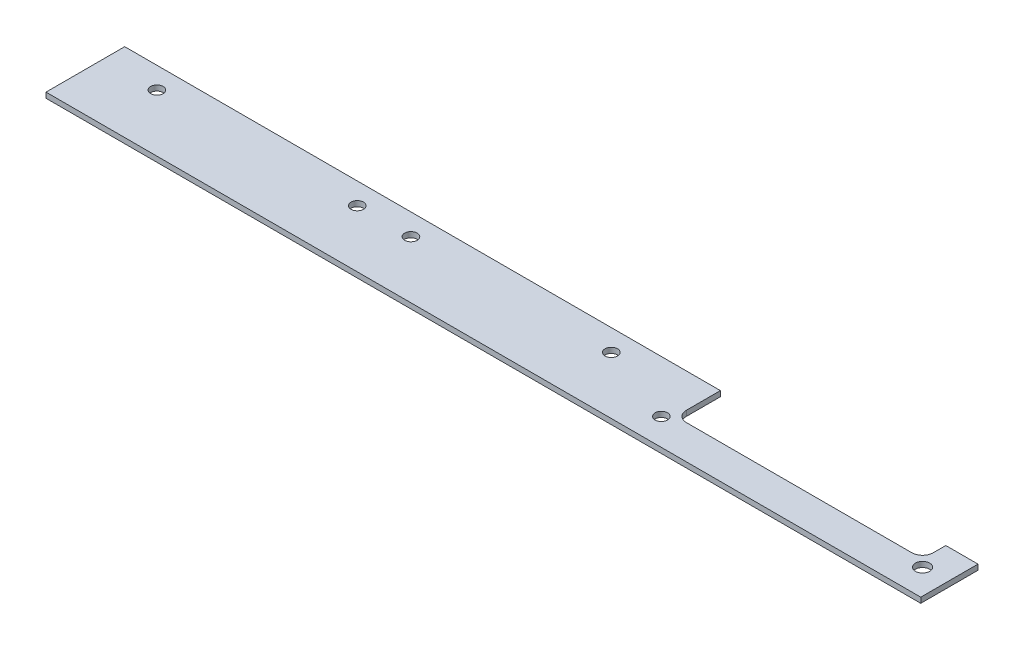
from build123d import *

# Parameters (mm, degrees)
SKETCH_1_R      = 1.75
SKETCH_1_R_2    = 2
EXTRUDE_1_DEPTH = 1.5


with BuildPart() as part:
    # Эскиз1 → Бобышка-Вытянуть1 (new body)
    with BuildSketch(Plane(origin=(0, 0, 0), x_dir=(1, 0, 0), z_dir=(0, 1, 0))):
        with BuildLine():
            Line((166.5, 12.5), (166.5, 22))
            Line((166.5, 22), (0, 22))
            Line((0, 22), (0, 0))
            Line((0, 0), (244.5, 0))
            Line((244.5, 0), (244.5, 16))
            Line((244.5, 16), (235.5, 16))
            Line((235.5, 16), (235.5, 12.5))
            ThreePointArc((235.5, 12.5), (234.621320344, 10.378679656), (232.5, 9.5))
            Line((232.5, 9.5), (169.5, 9.5))
            ThreePointArc((169.5, 9.5), (167.378679656, 10.378679656), (166.5, 12.5))
        make_face()
        with Locations((164.5, 7.5)):
            Circle(SKETCH_1_R, mode=Mode.SUBTRACT)
        with Locations((237.5, 7.5)):
            Circle(SKETCH_1_R_2, mode=Mode.SUBTRACT)
        with Locations((15, 16)):
            Circle(SKETCH_1_R, mode=Mode.SUBTRACT)
        with Locations((71, 16)):
            Circle(SKETCH_1_R, mode=Mode.SUBTRACT)
        with Locations((86, 16)):
            Circle(SKETCH_1_R, mode=Mode.SUBTRACT)
        with Locations((142, 16)):
            Circle(SKETCH_1_R, mode=Mode.SUBTRACT)
    extrude(amount=EXTRUDE_1_DEPTH)


solid = part.part
